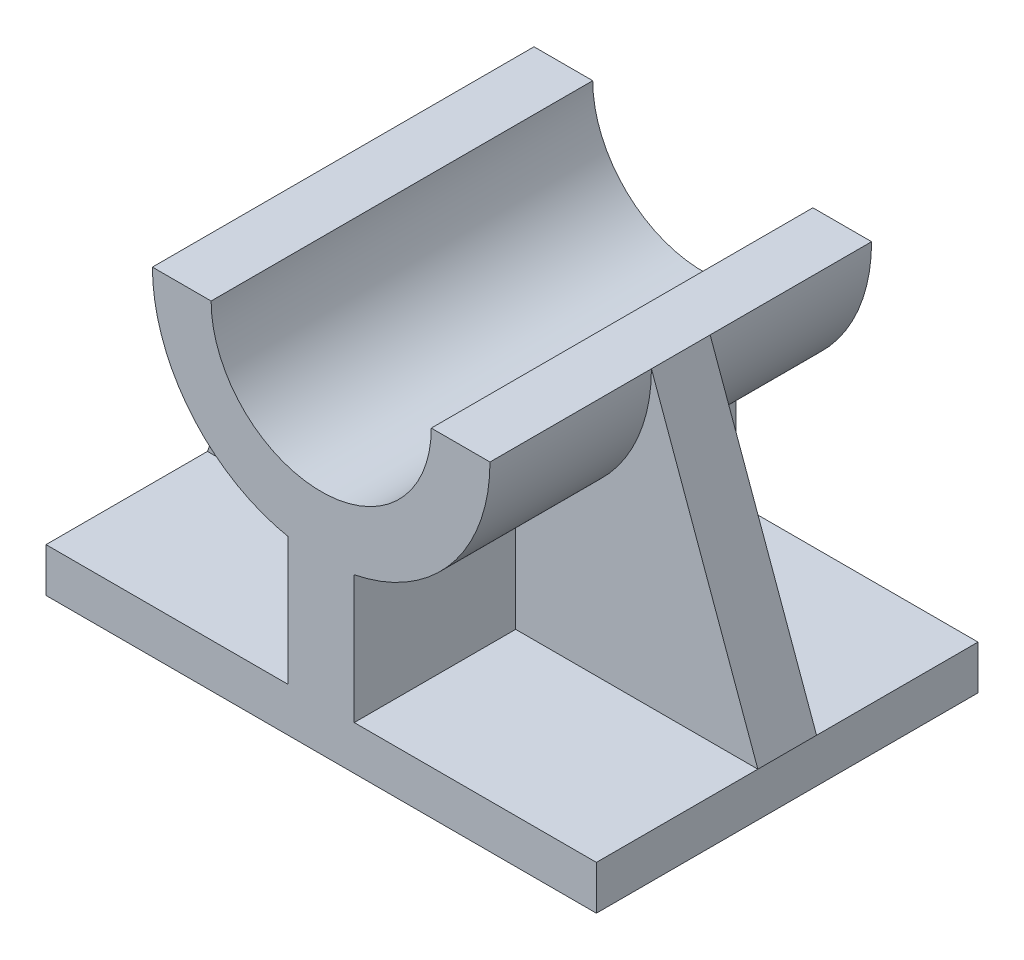
from build123d import *

# Parameters (mm, degrees)
SKETCH1_W           = 75
SKETCH1_H           = 52
BOSS_EXTRUDE1_DEPTH = 6
SKETCH2_W           = 9
SKETCH2_H           = 52
BOSS_EXTRUDE2_DEPTH = 17
BOSS_EXTRUDE3_DEPTH = 52
BOSS_EXTRUDE5_REACH = 53.1
SKETCH6_W           = 9
SKETCH6_H           = 52
RIB1_REACH          = 66.794
SKETCH7_WALL_W      = 174.134840868
SKETCH7_WALL_H      = 8


with BuildPart() as part:
    # Sketch1 → Boss-Extrude1 (new body)
    with BuildSketch(Plane(origin=(0, 0, 0), x_dir=(1, 0, 0), z_dir=(0, 1, 0))):
        Rectangle(SKETCH1_W, SKETCH1_H)
    extrude(amount=BOSS_EXTRUDE1_DEPTH)

    # Sketch2 → Boss-Extrude2 (add)
    with BuildSketch(Plane(origin=(0, 6, 0), x_dir=(1, 0, 0), z_dir=(0, 1, 0))):
        Rectangle(SKETCH2_W, SKETCH2_H)
    extrude(amount=BOSS_EXTRUDE2_DEPTH)


with BuildPart() as body_2:
    # Sketch3 → Boss-Extrude3 (new body)
    with BuildSketch(Plane.XY.offset(26)):
        with BuildLine():
            Line((-23, 46), (-15, 46))
            ThreePointArc((-15, 46), (0, 31), (15, 46))
            Line((15, 46), (23, 46))
            ThreePointArc((23, 46), (0, 23), (-23, 46))
        make_face()
    extrude(amount=-BOSS_EXTRUDE3_DEPTH)

    # Sketch6 → Boss-Extrude5 (add, up to next)
    with BuildSketch(Plane(origin=(0, 23, 0), x_dir=(1, 0, 0), z_dir=(0, 1, 0)), mode=Mode.PRIVATE) as boss_extrude5_sk1:
        Rectangle(SKETCH6_W, SKETCH6_H)
    boss_extrude5_tool1 = extrude(boss_extrude5_sk1.sketch, amount=BOSS_EXTRUDE5_REACH, mode=Mode.PRIVATE) - body_2.part

    add(part.part)  # Boss-Extrude5 merges part
    add(boss_extrude5_tool1.solids().sort_by_distance((0, 23, 0))[0])
    add(boss_extrude5_tool1.solids().sort_by_distance((0, 23, 0))[1])

    # Sketch7 wall → Rib1 (add, up to next)
    with BuildSketch(Plane(origin=(30.25, 26, 0), x_dir=(0.340799323621, -0.940136065162, 0), z_dir=(0.940136065162, 0.340799323621, 0)), mode=Mode.PRIVATE) as rib1_sk1:
        Rectangle(SKETCH7_WALL_W, SKETCH7_WALL_H)
    rib1_tool1 = extrude(rib1_sk1.sketch, amount=-RIB1_REACH, mode=Mode.PRIVATE) - body_2.part
    rib1 = rib1_tool1.solids().sort_by_distance((30.25, 26, 0))[0]
    add(rib1)

    # Mirror3: Rib1 across plane
    add(rib1.mirror(Plane(origin=(0, 0, 0), x_dir=(0, 0, 1), z_dir=(1, 0, 0))))


solid = body_2.part
